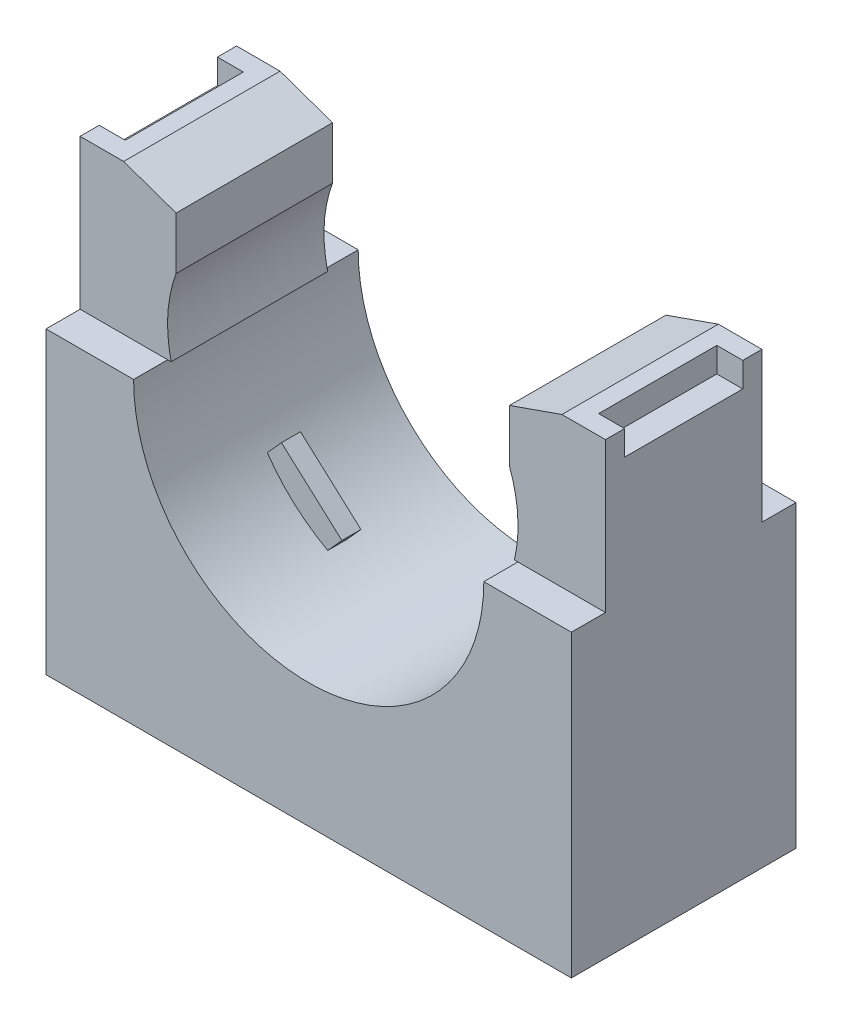
from build123d import *

# Parameters (mm, degrees)
SKETCH1_W               = 35.052
SKETCH1_H               = 29.972
EXTRUDE1_DEPTH          = 14.986
CUT_EXTRUDE1_DEPTH      = 15.986
SKETCH3_W               = 2.27457
SKETCH3_H               = 9.990666667
CUT_EXTRUDE2_DEPTH      = 18.526
CUT_EXTRUDE2_DEPTH_BACK = 18.526
SKETCH4_W               = 33.4645
SKETCH4_H               = 13.3985
CUT_EXTRUDE3_DEPTH      = 0.254
SKETCH5_W               = 1.731382872
SKETCH5_H               = 7.88543
CUT_EXTRUDE4_DEPTH      = 1.651
EXTRUDE2_DEPTH          = 0.635


with BuildPart() as part:
    # Sketch1 → Extrude1 (new body)
    with BuildSketch(Plane.XY):
        Rectangle(SKETCH1_W, SKETCH1_H)
    extrude(amount=EXTRUDE1_DEPTH)

    # Sketch2 → Cut-Extrude1 (cut, through all)
    with BuildSketch(Plane.XY.offset(14.986)):
        with BuildLine():
            Line((-11.684, 4.995333333), (-11.45032, 4.995333333))
            ThreePointArc((-11.45032, 4.995333333), (-11.673292179, 7.650930846), (-11.1204375, 10.257895833))
            Line((-11.1204375, 10.257895833), (-11.1204375, 13.758333333))
            Line((-11.1204375, 13.758333333), (-14.620875, 14.986))
            Line((-14.620875, 14.986), (14.620875, 14.986))
            Line((14.620875, 14.986), (11.1204375, 13.758333333))
            Line((11.1204375, 13.758333333), (11.1204375, 10.257895833))
            ThreePointArc((11.1204375, 10.257895833), (11.673292179, 7.650930846), (11.45032, 4.995333333))
            Line((11.45032, 4.995333333), (11.684, 4.995333333))
            ThreePointArc((11.684, 4.995333333), (0, -6.688666667), (-11.684, 4.995333333))
        make_face()
    extrude(amount=-CUT_EXTRUDE1_DEPTH, mode=Mode.SUBTRACT)

    # Sketch3 → Cut-Extrude2 (cut, two sides)
    with BuildSketch(Plane(origin=(0, 0, 0), x_dir=(0, 0, -1), z_dir=(1, 0, 0))) as cut_extrude2_sk:
        with Locations((-13.848715, 9.990666667)):
            Rectangle(SKETCH3_W, SKETCH3_H)
        with Locations((-1.137285, 9.990666667)):
            Rectangle(SKETCH3_W, SKETCH3_H)
    extrude(amount=CUT_EXTRUDE2_DEPTH, mode=Mode.SUBTRACT)
    extrude(cut_extrude2_sk.sketch, amount=-CUT_EXTRUDE2_DEPTH_BACK, mode=Mode.SUBTRACT)

    # Sketch4 → Cut-Extrude3 (cut)
    with BuildSketch(Plane.XZ.offset(14.986)):
        with Locations((0, 7.493)):
            Rectangle(SKETCH4_W, SKETCH4_H)
    extrude(amount=-CUT_EXTRUDE3_DEPTH, mode=Mode.SUBTRACT)

    # Sketch5 → Cut-Extrude4 (cut)
    with BuildSketch(Plane(origin=(0, 14.986, 0), x_dir=(1, 0, 0), z_dir=(0, 1, 0))):
        with Locations((-16.660308564, -7.493)):
            Rectangle(SKETCH5_W, SKETCH5_H)
        with Locations((16.660308564, -7.493)):
            Rectangle(SKETCH5_W, SKETCH5_H)
    extrude(amount=-CUT_EXTRUDE4_DEPTH, mode=Mode.SUBTRACT)

    # Sketch6 → Cut-Revolve1 (revolve, cut)
    with BuildSketch(Plane(origin=(0, 0, 7.493), x_dir=(-1, 0, 0), z_dir=(0, 0, -1)), mode=Mode.PRIVATE) as cut_revolve1_sk:
        Polygon((3.048, -14.732), (0, -14.732), (0, -8.636), (5.969, -8.636), (5.969, -11.684), (3.048, -11.684), align=None)
    revolve(cut_revolve1_sk.sketch.rotate(Axis((0, 0, 7.493), (0, -1, 0)), 270), axis=Axis((0, 0, 7.493), (0, -1, 0)), mode=Mode.SUBTRACT)  # turned: the seam where the file's is

    # Sketch7 → Extrude2 (add, symmetric)
    with BuildSketch(Plane(origin=(0, 0, 7.493), x_dir=(-1, 0, 0), z_dir=(0, 0, -1))):
        with BuildLine():
            Line((4.641424464, -4.216434167), (8.676143507, -0.583556822))
            Line((8.676143507, -0.583556822), (9.621541413, -1.633527567))
            ThreePointArc((9.621541413, -1.633527567), (7.818122005, -3.687570808), (5.586822369, -5.266404912))
            Line((5.586822369, -5.266404912), (4.641424464, -4.216434167))
        make_face()
        with BuildLine():
            Line((-4.641424464, -4.216434167), (-5.586822369, -5.266404912))
            ThreePointArc((-5.586822369, -5.266404912), (-7.818122005, -3.687570808), (-9.621541413, -1.633527567))
            Line((-9.621541413, -1.633527567), (-8.676143507, -0.583556822))
            Line((-8.676143507, -0.583556822), (-4.641424464, -4.216434167))
        make_face()
    extrude(amount=EXTRUDE2_DEPTH, both=True)


solid = part.part
